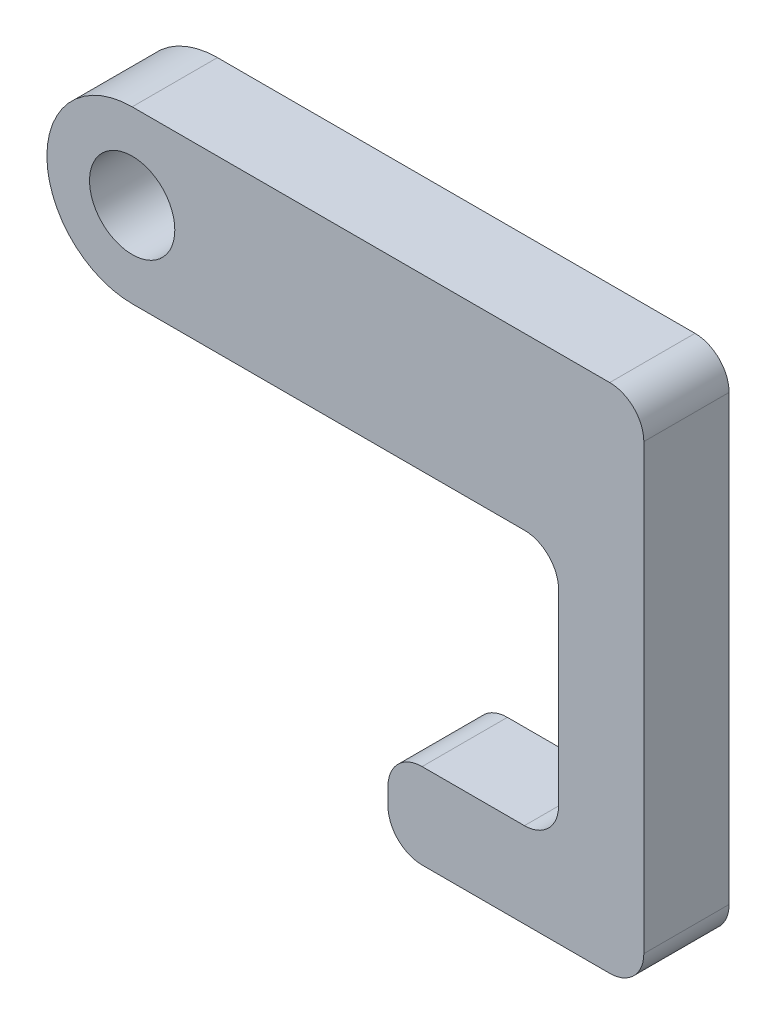
from build123d import *

# Parameters (mm, degrees)
ESQUISSE1_R        = 2.5
BOSS_EXTRU_1_DEPTH = 5
CONG_1_R           = 2


with BuildPart() as part:
    # Esquisse1 → Boss.-Extru.1 (new body)
    with BuildSketch(Plane.XY):
        with BuildLine():
            Line((10, -5), (10, -20))
            Line((10, -20), (0, -20))
            Line((0, -20), (0, -25))
            Line((0, -25), (15, -25))
            Line((15, -25), (15, -5))
            Line((15, -5), (15, 5))
            Line((15, 5), (-15, 5))
            ThreePointArc((-15, 5), (-20, 0), (-15, -5))
            Line((-15, -5), (10, -5))
        make_face()
        with Locations((-15, 0)):
            Circle(ESQUISSE1_R, mode=Mode.SUBTRACT)
    extrude(amount=BOSS_EXTRU_1_DEPTH)

    # Congé1
    cong_1_edges = [part.edges().sort_by_distance(p)[0] for p in [
        (15, -25, 2.5),
        (0, -25, 2.5),
        (0, -20, 2.5),
        (10, -20, 2.5),
        (10, -5, 2.5),
        (15, 5, 2.5),
    ]]
    fillet(cong_1_edges, radius=CONG_1_R)


solid = part.part
